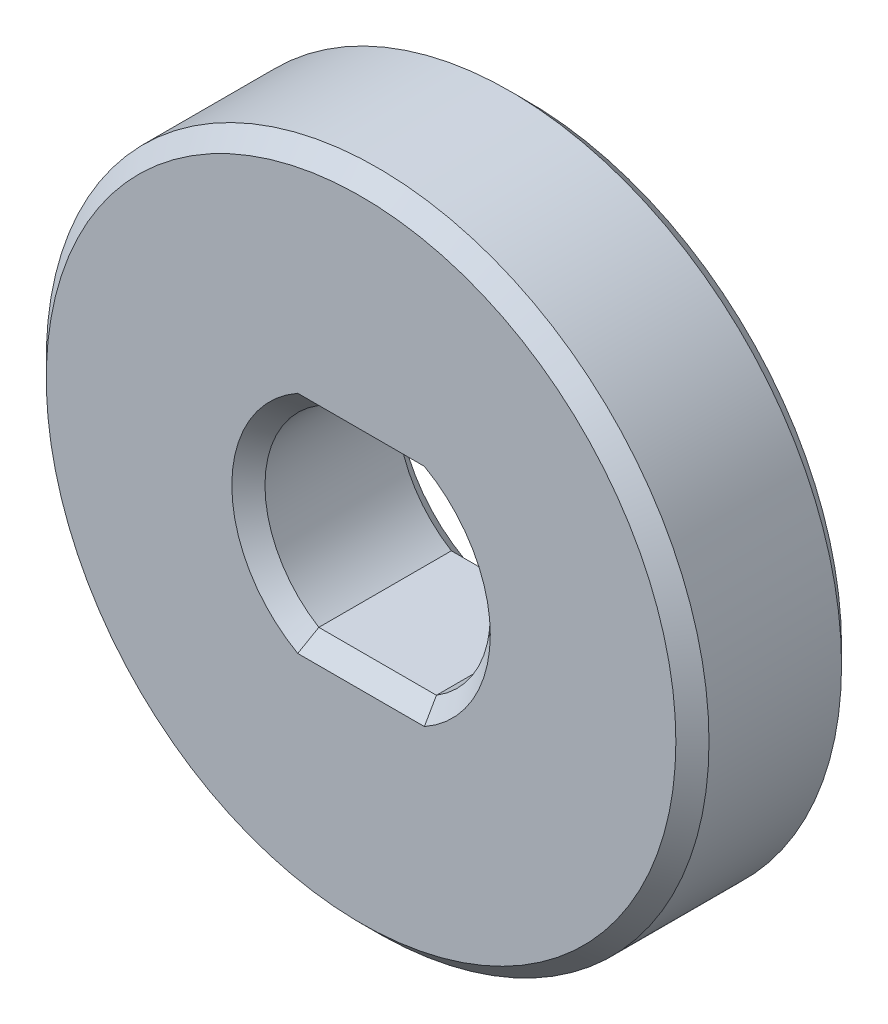
from build123d import *

# Parameters (mm, degrees)
SKETCH1_R           = 10
BOSS_EXTRUDE1_DEPTH = 5
CHAMFER1_SIZE       = 0.5


with BuildPart() as part:
    # Sketch1 → Boss-Extrude1 (new body)
    with BuildSketch(Plane.XY):
        Circle(SKETCH1_R)
        with BuildLine():
            Line((-1.774823935, 2.9), (1.774823935, 2.9))
            ThreePointArc((1.774823935, 2.9), (3.4, 0), (1.774823935, -2.9))
            Line((1.774823935, -2.9), (-1.774823935, -2.9))
            ThreePointArc((-1.774823935, -2.9), (-3.4, 0), (-1.774823935, 2.9))
        make_face(mode=Mode.SUBTRACT)
    extrude(amount=BOSS_EXTRUDE1_DEPTH)

    # Chamfer1
    chamfer1_edges = [part.edges().sort_by_distance(p)[0] for p in [
        (3.4, 0, 5),
        (0, 2.9, 5),
        (-10, 0, 0),
        (-10, 0, 5),
        (-3.4, 0, 0),
        (0, -2.9, 0),
        (3.4, 0, 0),
        (0, 2.9, 0),
        (-3.4, 0, 5),
        (0, -2.9, 5),
    ]]
    chamfer(chamfer1_edges, length=CHAMFER1_SIZE)


solid = part.part
